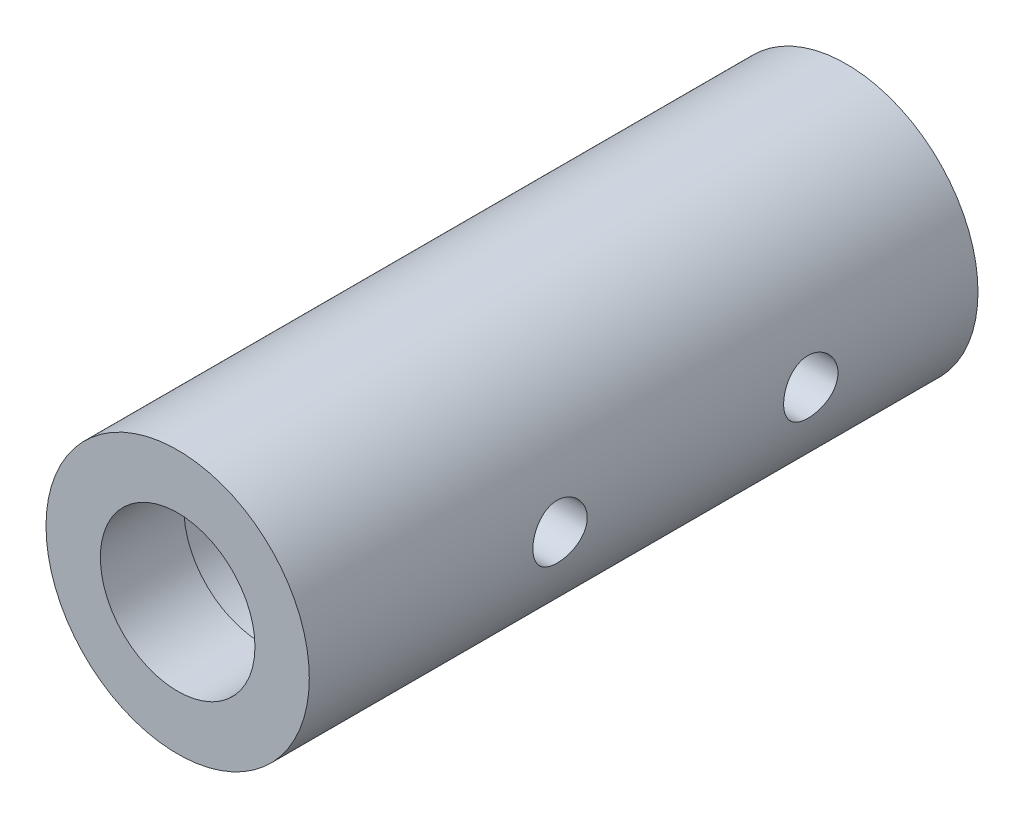
from build123d import *

# Parameters (mm, degrees)
BOSS_EXTRUDE1_DEPTH      = 16
BOSS_EXTRUDE1_DEPTH_BACK = 16
SKETCH1_R                = 6.3
SKETCH1_R_2              = 4.2
CUT_EXTRUDE1_DEPTH       = 14
CUT_EXTRUDE1_DEPTH_BACK  = 10
SKETCH2_R                = 1.3
SKETCH3_R                = 4.2
SKETCH3_R_2              = 3.7
BOSS_EXTRUDE2_DEPTH      = 4


with BuildPart() as part:
    # Sketch1 → Boss-Extrude1 (new, two sides: drawn at the far end of the back side and taken through both)
    with BuildSketch(Plane.XY.offset(-BOSS_EXTRUDE1_DEPTH_BACK)):
        Circle(SKETCH1_R)
        Circle(SKETCH1_R_2, mode=Mode.SUBTRACT)
    extrude(amount=BOSS_EXTRUDE1_DEPTH + BOSS_EXTRUDE1_DEPTH_BACK)

    # Sketch2 → Cut-Extrude1 (cut, two sides: drawn at the far end of the back side and taken through both)
    with BuildSketch(Plane(origin=(0, 0, 0), x_dir=(0, 0, -1), z_dir=(1, 0, 0)).offset(-CUT_EXTRUDE1_DEPTH_BACK)):
        with Locations((-4, 0)):
            Circle(SKETCH2_R)
        with Locations((8, 0)):
            Circle(SKETCH2_R)
    extrude(amount=CUT_EXTRUDE1_DEPTH + CUT_EXTRUDE1_DEPTH_BACK, mode=Mode.SUBTRACT)

    # Sketch3 → Boss-Extrude2 (add)
    with BuildSketch(Plane.XY.offset(16)):
        Circle(SKETCH3_R)
        Circle(SKETCH3_R_2, mode=Mode.SUBTRACT)
    extrude(amount=-BOSS_EXTRUDE2_DEPTH)


solid = part.part
